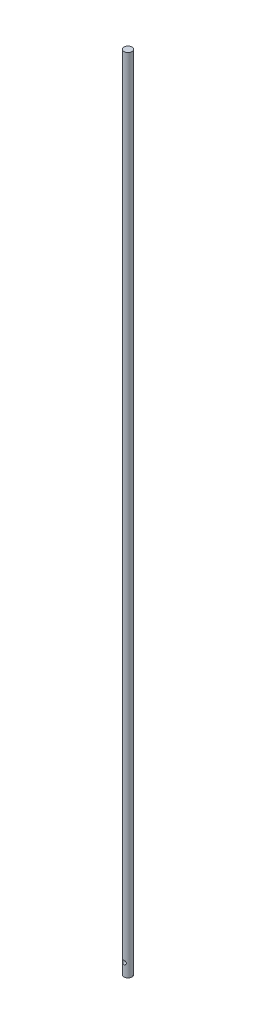
from build123d import *

# Parameters (mm, degrees)
SKETCH1_R               = 3.175
BOSS_EXTRUDE1_DEPTH     = 635
SKETCH2_R               = 1.5
CUT_EXTRUDE1_DEPTH      = 4.175
CUT_EXTRUDE1_DEPTH_BACK = 4.175


with BuildPart() as part:
    # Sketch1 → Boss-Extrude1 (new body)
    with BuildSketch(Plane(origin=(0, 0, 0), x_dir=(1, 0, 0), z_dir=(0, 1, 0))):
        Circle(SKETCH1_R)
    extrude(amount=BOSS_EXTRUDE1_DEPTH)

    # Sketch2 → Cut-Extrude1 (cut, two sides)
    with BuildSketch(Plane(origin=(0, 6.35, 0), x_dir=(-1, 0, 0), z_dir=(0, 0, 1))) as cut_extrude1_sk:
        with Locations((0, -3.65)):
            Circle(SKETCH2_R)
    extrude(amount=CUT_EXTRUDE1_DEPTH, mode=Mode.SUBTRACT)
    extrude(cut_extrude1_sk.sketch, amount=-CUT_EXTRUDE1_DEPTH_BACK, mode=Mode.SUBTRACT)


solid = part.part
